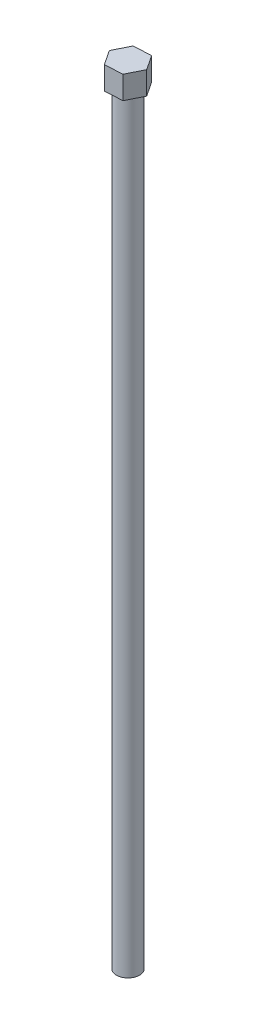
from build123d import *

# Parameters (mm, degrees)
SKETCH2_R           = 1.5
BOSS_EXTRUDE1_DEPTH = 100
BOSS_EXTRUDE2_DEPTH = 3


with BuildPart() as part:
    # Sketch2 → Boss-Extrude1 (new body)
    with BuildSketch(Plane(origin=(0, 0, 0), x_dir=(1, 0, 0), z_dir=(0, 1, 0))):
        Circle(SKETCH2_R)
    extrude(amount=BOSS_EXTRUDE1_DEPTH)

    # Sketch3 → Boss-Extrude2 (add)
    with BuildSketch(Plane(origin=(0, 100, 0), x_dir=(1, 0, 0), z_dir=(0, 1, 0))):
        Polygon((-2.305280672, -0.137892556), (-1.03322188, -2.065377903), (1.272058792, -1.927485347), (2.305280672, 0.137892556), (1.03322188, 2.065377903), (-1.272058792, 1.927485347), align=None)
    extrude(amount=BOSS_EXTRUDE2_DEPTH)


solid = part.part
